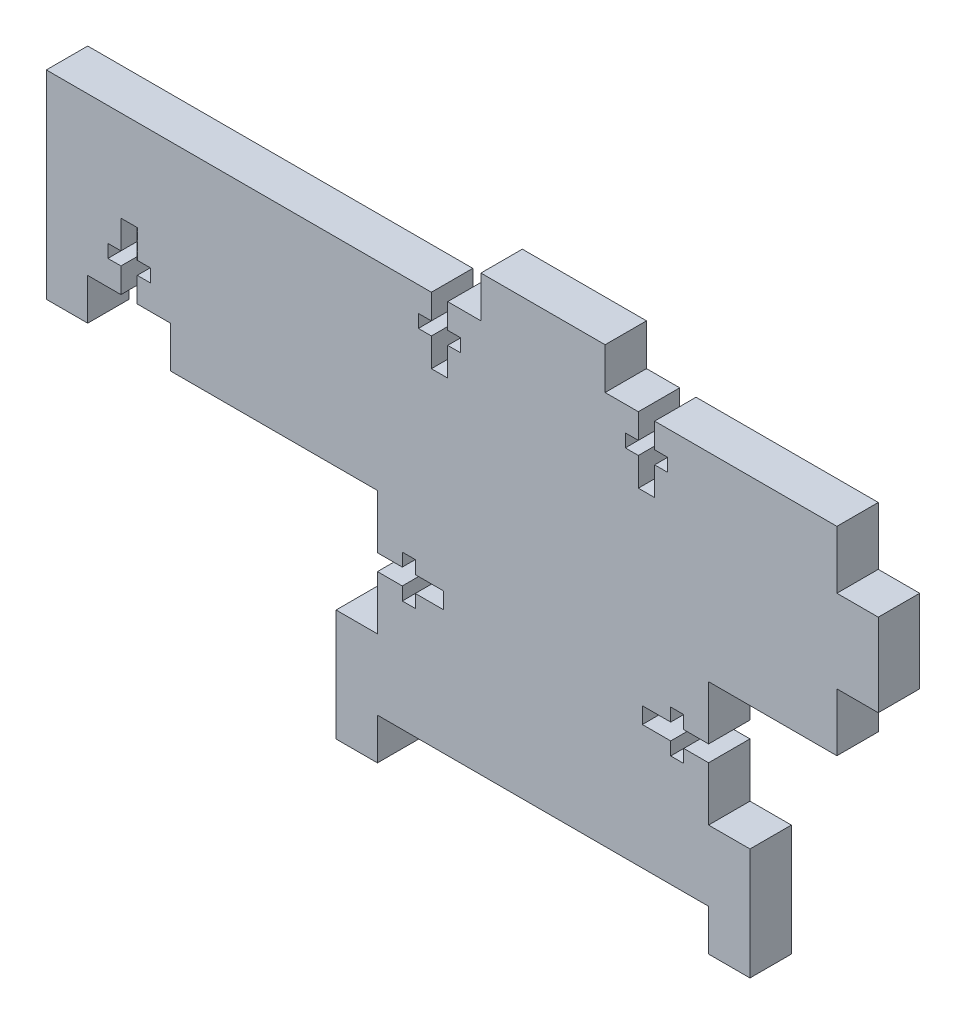
from build123d import *

# Parameters (mm, degrees)
BOSS_EXTRUDE1_DEPTH = 6.35
SKETCH2_W           = 12.7
SKETCH2_H           = 6.35
CUT_EXTRUDE1_DEPTH  = 7.35
CUT_EXTRUDE2_DEPTH  = 7.35
CUT_EXTRUDE3_DEPTH  = 7.35


with BuildPart() as part:
    # Sketch1 → Boss-Extrude1 (new body)
    with BuildSketch(Plane.XY):
        Polygon((0, 0), (19.05, 0), (34.925, 0), (34.925, -6.35), (41.275, -6.35), (41.275, 0), (41.275, 10.795), (34.925, 10.795), (34.925, 29.845), (54.61, 29.845), (54.61, 38.735), (60.96, 38.735), (60.96, 51.435), (54.61, 51.435), (54.61, 60.325), (34.925, 60.325), (19.05, 60.325), (19.05, 66.675), (0, 66.675), (0, 60.325), (-15.875, 60.325), (-66.675, 60.325), (-66.675, 29.845), (-15.875, 29.845), (-15.875, 10.795), (-22.225, 10.795), (-22.225, 0), (-22.225, -6.35), (-15.875, -6.35), (-15.875, 0), align=None)
    extrude(amount=BOSS_EXTRUDE1_DEPTH)

    # Sketch2 → Cut-Extrude1 (cut, through all)
    with BuildSketch(Plane.XY.offset(6.35)):
        with Locations((-53.975, 33.02)):
            Rectangle(SKETCH2_W, SKETCH2_H)
    extrude(amount=-CUT_EXTRUDE1_DEPTH, mode=Mode.SUBTRACT)

    # Sketch3 → Cut-Extrude2 (cut, through all)
    with BuildSketch(Plane.XY.offset(6.35)):
        Polygon((-15.875, 21.57), (-15.875, 19.07), (-12.065, 19.07), (-12.065, 17.07), (-10.065, 17.07), (-10.065, 19.07), (-5.715, 19.07), (-5.715, 21.57), (-10.065, 21.57), (-10.065, 23.57), (-12.065, 23.57), (-12.065, 21.57), align=None)
        Polygon((34.925, 21.57), (34.925, 19.07), (31.115, 19.07), (31.115, 17.07), (29.115, 17.07), (29.115, 19.07), (24.765, 19.07), (24.765, 21.57), (29.115, 21.57), (29.115, 23.57), (31.115, 23.57), (31.115, 21.57), align=None)
    extrude(amount=-CUT_EXTRUDE2_DEPTH, mode=Mode.SUBTRACT)

    # Sketch5 → Cut-Extrude3 (cut, through all)
    with BuildSketch(Plane.XY.offset(6.35)):
        Polygon((-3.1, 56.515), (-3.1, 54.515), (-5.1, 54.515), (-5.1, 50.165), (-7.6, 50.165), (-7.6, 54.515), (-9.6, 54.515), (-9.6, 56.515), (-7.6, 56.515), (-7.6, 60.325), (-5.1, 60.325), (-5.1, 56.515), align=None)
        Polygon((-52.725, 42.005), (-50.725, 42.005), (-50.725, 40.005), (-52.725, 40.005), (-52.725, 36.195), (-55.225, 36.195), (-55.225, 40.005), (-57.225, 40.005), (-57.225, 42.005), (-55.225, 42.005), (-55.225, 46.355), (-52.725, 46.355), align=None)
        Polygon((26.65, 60.325), (26.65, 56.515), (28.65, 56.515), (28.65, 54.515), (26.65, 54.515), (26.65, 50.165), (24.15, 50.165), (24.15, 54.515), (22.15, 54.515), (22.15, 56.515), (24.15, 56.515), (24.15, 60.325), align=None)
    extrude(amount=-CUT_EXTRUDE3_DEPTH, mode=Mode.SUBTRACT)


solid = part.part
